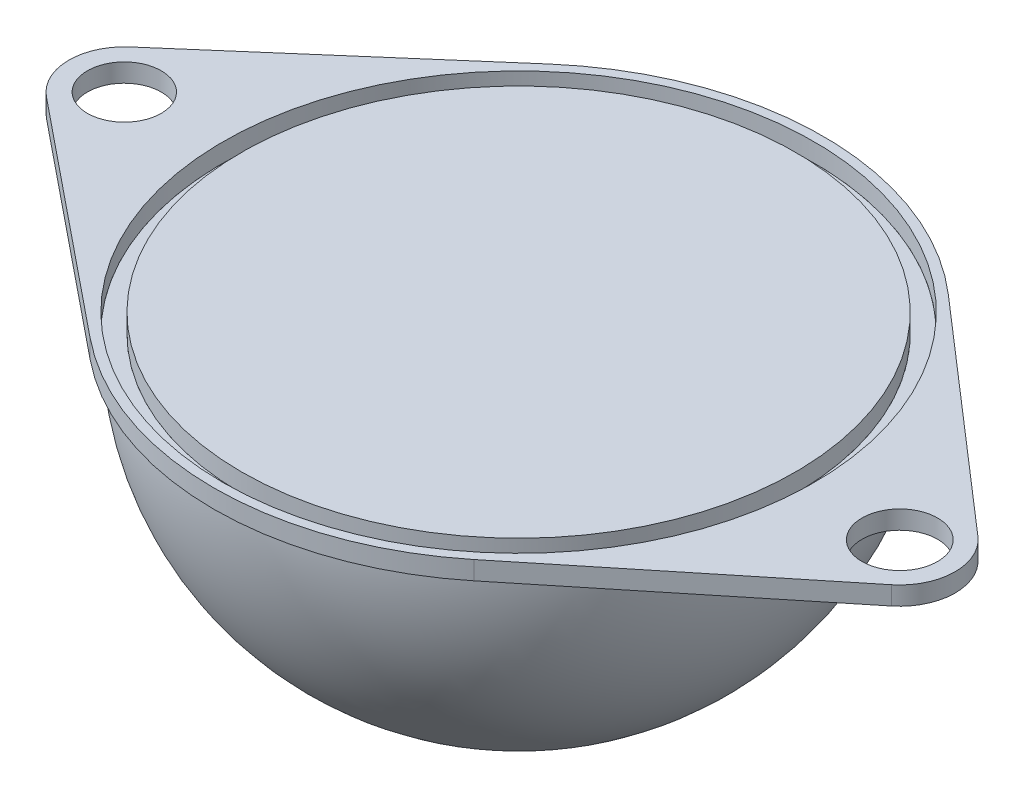
from build123d import *

# Parameters (mm, degrees)
REVOLVE6_ANGLE          = 180
SKETCH1_9_R             = 2
BOSS_EXTRUDE1_DEPTH     = 1
SKETCH1_9_R_2           = 15
BOSS_EXTRUDE1_2_DEPTH   = 1
CUT_EXTRUDE1_REACH      = 35.231
CUT_EXTRUDE1_END_RADIUS = 16
SKETCH2_R               = 7.5
SCALE2_SCALE            = 0.5


with BuildPart() as part:
    # Sketch1 → Revolve6 (revolve)
    with BuildSketch(Plane(origin=(0, 0, 0), x_dir=(1, 0, 0), z_dir=(0, 1, 0))):
        with BuildLine():
            ThreePointArc((-16, 0), (0, -16), (16, 0))
            Line((16, 0), (15, 0))
            ThreePointArc((15, 0), (0, -15), (-15, 0))
            Line((-15, 0), (-16, 0))
        make_face()
    revolve(axis=Axis((-19.031531421, 0, 0), (1, 0, 0)), revolution_arc=REVOLVE6_ANGLE)

    # Cut-Extrude1: up to this sphere (the profile starts inside it)
    cut_extrude1_end = Location((0, 0, 0)) * Sphere(CUT_EXTRUDE1_END_RADIUS, mode=Mode.PRIVATE)
    # Sketch2 → Cut-Extrude1 (cut, up to the surface)
    with BuildSketch(Plane(origin=(0, 0, 0), x_dir=(1, 0, 0), z_dir=(0, 1, 0)), mode=Mode.PRIVATE) as cut_extrude1_sk1:
        Circle(SKETCH2_R)
    cut_extrude1_tool1 = extrude(cut_extrude1_sk1.sketch, amount=-CUT_EXTRUDE1_REACH, mode=Mode.PRIVATE) & cut_extrude1_end
    add(cut_extrude1_tool1.solids().sort_by_distance((0, 0, 0))[0], mode=Mode.SUBTRACT)


with BuildPart() as body_2:
    # Sketch1_9 → Boss-Extrude1 (new body)
    with BuildSketch(Plane(origin=(0, 0, 0), x_dir=(1, 0, 0), z_dir=(0, 1, 0))):
        with BuildLine():
            ThreePointArc((-22.96695029, 1.912018961), (-24, -0.404273426), (-22.889523883, -2.684458707))
            Line((-22.889523883, -2.684458707), (-10.390907276, -12.81713876))
            ThreePointArc((-10.390907276, -12.81713876), (0, -16.5), (10.390907276, -12.81713876))
            Line((10.390907276, -12.81713876), (22.889523883, -2.684458707))
            ThreePointArc((22.889523883, -2.684458707), (23.780005188, -1.48251064), (23.979500335, 0))
            ThreePointArc((23.979500335, 0), (23.651565118, 1.050453093), (22.96695029, 1.912018961))
            Line((22.96695029, 1.912018961), (10.816692113, 12.459902557))
            ThreePointArc((10.816692113, 12.459902557), (0, 16.5), (-10.816692113, 12.459902557))
            Line((-10.816692113, 12.459902557), (-22.96695029, 1.912018961))
        make_face()
        with Locations((-21, -0.353739248)):
            Circle(SKETCH1_9_R, mode=Mode.SUBTRACT)
        with BuildLine():
            ThreePointArc((18.984689587, 0), (21, 1.692380865), (23.015310413, 0))
            ThreePointArc((23.015310413, 0), (21, -2.39985936), (18.984689587, 0))
        make_face(mode=Mode.SUBTRACT)
        with BuildLine():
            ThreePointArc((-16, 0), (0, 16), (16, 0))
            ThreePointArc((16, 0), (0, -16), (-16, 0))
        make_face(mode=Mode.SUBTRACT)
    extrude(amount=BOSS_EXTRUDE1_DEPTH)


with BuildPart() as body_3:
    # Sketch1_9 → Boss-Extrude1 2 (new body)
    with BuildSketch(Plane(origin=(0, 0, 0), x_dir=(1, 0, 0), z_dir=(0, 1, 0))):
        Circle(SKETCH1_9_R_2)
    extrude(amount=BOSS_EXTRUDE1_2_DEPTH)


with BuildPart() as body_2_1:
    # Scale2: scaled about (0, 0, 0)
    add(body_2.part.scale(SCALE2_SCALE))


with BuildPart() as body_3_1:
    # Scale2: scaled about (0, 0, 0)
    add(body_3.part.scale(SCALE2_SCALE))


with BuildPart() as part_1:
    # Scale2: scaled about (0, 0, 0)
    add(part.part.scale(SCALE2_SCALE))


solid = Compound([body_2_1.part, body_3_1.part, part_1.part])
